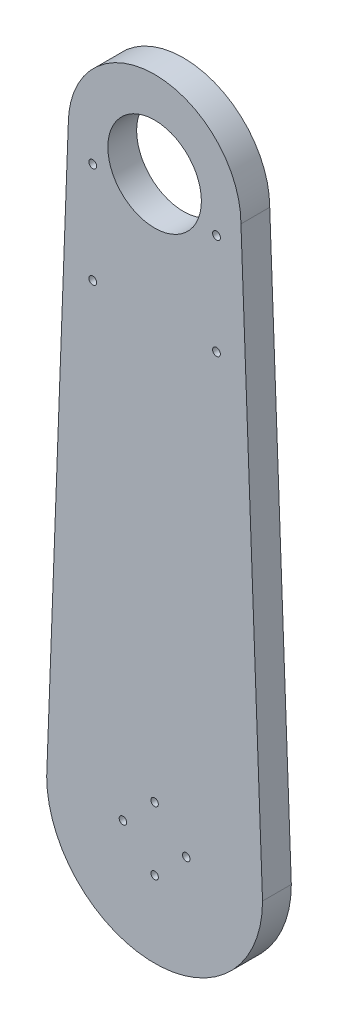
from build123d import *

# Parameters (mm, degrees)
BOSS_EXTRUDE1_DEPTH = 10
CUT_EXTRUDE4_REACH  = 12
SKETCH3_R           = 16.25
CUT_EXTRUDE5_REACH  = 12
SKETCH4_R           = 1.3
SKETCH5_R           = 1.35
CUT_EXTRUDE6_DEPTH  = 10


with BuildPart() as part:
    # Sketch1 → Boss-Extrude1 (new body)
    with BuildSketch(Plane.XY):
        with BuildLine():
            ThreePointArc((30, 200), (0, 230), (-30, 200))
            Line((-30, 200), (-37.5, 0))
            ThreePointArc((-37.5, 0), (0, -37.5), (37.5, 0))
            Line((37.5, 0), (30, 200))
        make_face()
    extrude(amount=BOSS_EXTRUDE1_DEPTH)

    # Sketch3 → Cut-Extrude4 (cut, up to next)
    with BuildSketch(Plane(origin=(0, 0, 0), x_dir=(-1, 0, 0), z_dir=(0, 0, -1)), mode=Mode.PRIVATE) as cut_extrude4_sk1:
        with Locations((0, 200)):
            Circle(SKETCH3_R)
    cut_extrude4_tool1 = extrude(cut_extrude4_sk1.sketch, amount=-CUT_EXTRUDE4_REACH, mode=Mode.PRIVATE) & part.part
    add(cut_extrude4_tool1.solids().sort_by_distance((0, 200, 0))[0], mode=Mode.SUBTRACT)

    # Sketch4 → Cut-Extrude5 (cut, up to next)
    with BuildSketch(Plane(origin=(0, 0, 0), x_dir=(-1, 0, 0), z_dir=(0, 0, -1)), mode=Mode.PRIVATE) as cut_extrude5_sk1:
        with Locations((0, 11)):
            Circle(SKETCH4_R)
    cut_extrude5_tool1 = extrude(cut_extrude5_sk1.sketch, amount=-CUT_EXTRUDE5_REACH, mode=Mode.PRIVATE) & part.part
    add(cut_extrude5_tool1.solids().sort_by_distance((0, 11, 0))[0], mode=Mode.SUBTRACT)
    # Sketch4 → Cut-Extrude5 (cut, up to next)
    with BuildSketch(Plane(origin=(0, 0, 0), x_dir=(-1, 0, 0), z_dir=(0, 0, -1)), mode=Mode.PRIVATE) as cut_extrude5_sk2:
        with Locations((11, 0)):
            Circle(SKETCH4_R)
    cut_extrude5_tool2 = extrude(cut_extrude5_sk2.sketch, amount=-CUT_EXTRUDE5_REACH, mode=Mode.PRIVATE) & part.part
    add(cut_extrude5_tool2.solids().sort_by_distance((-11, 0, 0))[0], mode=Mode.SUBTRACT)
    # Sketch4 → Cut-Extrude5 (cut, up to next)
    with BuildSketch(Plane(origin=(0, 0, 0), x_dir=(-1, 0, 0), z_dir=(0, 0, -1)), mode=Mode.PRIVATE) as cut_extrude5_sk3:
        with Locations((0, -11)):
            Circle(SKETCH4_R)
    cut_extrude5_tool3 = extrude(cut_extrude5_sk3.sketch, amount=-CUT_EXTRUDE5_REACH, mode=Mode.PRIVATE) & part.part
    add(cut_extrude5_tool3.solids().sort_by_distance((0, -11, 0))[0], mode=Mode.SUBTRACT)
    # Sketch4 → Cut-Extrude5 (cut, up to next)
    with BuildSketch(Plane(origin=(0, 0, 0), x_dir=(-1, 0, 0), z_dir=(0, 0, -1)), mode=Mode.PRIVATE) as cut_extrude5_sk4:
        with Locations((-11, 0)):
            Circle(SKETCH4_R)
    cut_extrude5_tool4 = extrude(cut_extrude5_sk4.sketch, amount=-CUT_EXTRUDE5_REACH, mode=Mode.PRIVATE) & part.part
    add(cut_extrude5_tool4.solids().sort_by_distance((11, 0, 0))[0], mode=Mode.SUBTRACT)

    # Sketch5 → Cut-Extrude6 (cut)
    with BuildSketch(Plane(origin=(0, 0, 0), x_dir=(-1, 0, 0), z_dir=(0, 0, -1))):
        with Locations((21.5, 157.25)):
            Circle(SKETCH5_R)
        with Locations((-21.5, 157.25)):
            Circle(SKETCH5_R)
        with Locations((-21.5, 192.25)):
            Circle(SKETCH5_R)
        with Locations((21.5, 192.25)):
            Circle(SKETCH5_R)
    extrude(amount=-CUT_EXTRUDE6_DEPTH, mode=Mode.SUBTRACT)


solid = part.part
